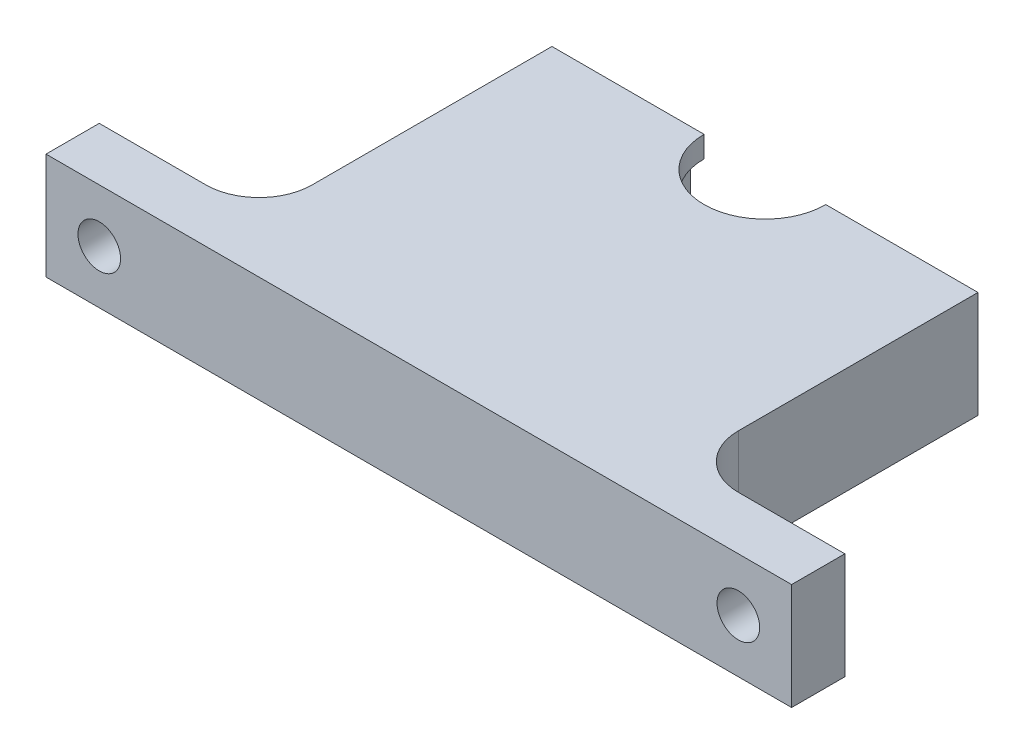
from build123d import *

# Parameters (mm, degrees)
MAIN_BODY_DEPTH       = 5
SKETCH3_R             = 6.985
BEARING_CUTOUT_DEPTH  = 3
SKETCH4_R             = 1.5
TOP_MOUNT_HOLES_DEPTH = 10
SKETCH6_W             = 15
SKETCH6_H             = 10
SKETCH6_R             = 2
MOUNTING_HOLES_DEPTH  = 5
FILLET1_R             = 5


with BuildPart() as part:
    # Sketch1 → main body (new body, symmetric)
    with BuildSketch(Plane(origin=(0, 0, 0), x_dir=(1, 0, 0), z_dir=(0, 1, 0))):
        with BuildLine():
            Line((20, 0), (12.7, 0))
            Line((12.7, 0), (5.715, 0))
            ThreePointArc((5.715, 0), (0, -5.715), (-5.715, 0))
            Line((-5.715, 0), (-12.7, 0))
            Line((-12.7, 0), (-20, 0))
            Line((-20, 0), (-20, -32.5))
            Line((-20, -32.5), (20, -32.5))
            Line((20, -32.5), (20, 0))
        make_face()
    extrude(amount=MAIN_BODY_DEPTH, both=True)

    # Sketch3 → bearing cutout (cut, symmetric)
    with BuildSketch(Plane(origin=(0, 0, 0), x_dir=(1, 0, 0), z_dir=(0, 1, 0))):
        Circle(SKETCH3_R)
    extrude(amount=BEARING_CUTOUT_DEPTH, both=True, mode=Mode.SUBTRACT)

    # Sketch4 → top mount holes (cut)
    with BuildSketch(Plane(origin=(0, 0, 0), x_dir=(-1, 0, 0), z_dir=(0, 0, -1))):
        with Locations((-15, 0)):
            Circle(SKETCH4_R)
        with Locations((15, 0)):
            Circle(SKETCH4_R)
    extrude(amount=-TOP_MOUNT_HOLES_DEPTH, mode=Mode.SUBTRACT)

    # Sketch6 → mounting holes (add)
    with BuildSketch(Plane.XY.offset(32.5)):
        with Locations((-27.5, 0)):
            Rectangle(SKETCH6_W, SKETCH6_H)
        with Locations((-30, 0)):
            Circle(SKETCH6_R, mode=Mode.SUBTRACT)
        with Locations((27.5, 0)):
            Rectangle(SKETCH6_W, SKETCH6_H)
        with Locations((30, 0)):
            Circle(SKETCH6_R, mode=Mode.SUBTRACT)
    extrude(amount=-MOUNTING_HOLES_DEPTH)

    # Fillet1
    fillet1_edges = [part.edges().sort_by_distance(p)[0] for p in [
        (-20, 0, 27.5),
        (20, 0, 27.5),
    ]]
    fillet(fillet1_edges, radius=FILLET1_R)


solid = part.part
